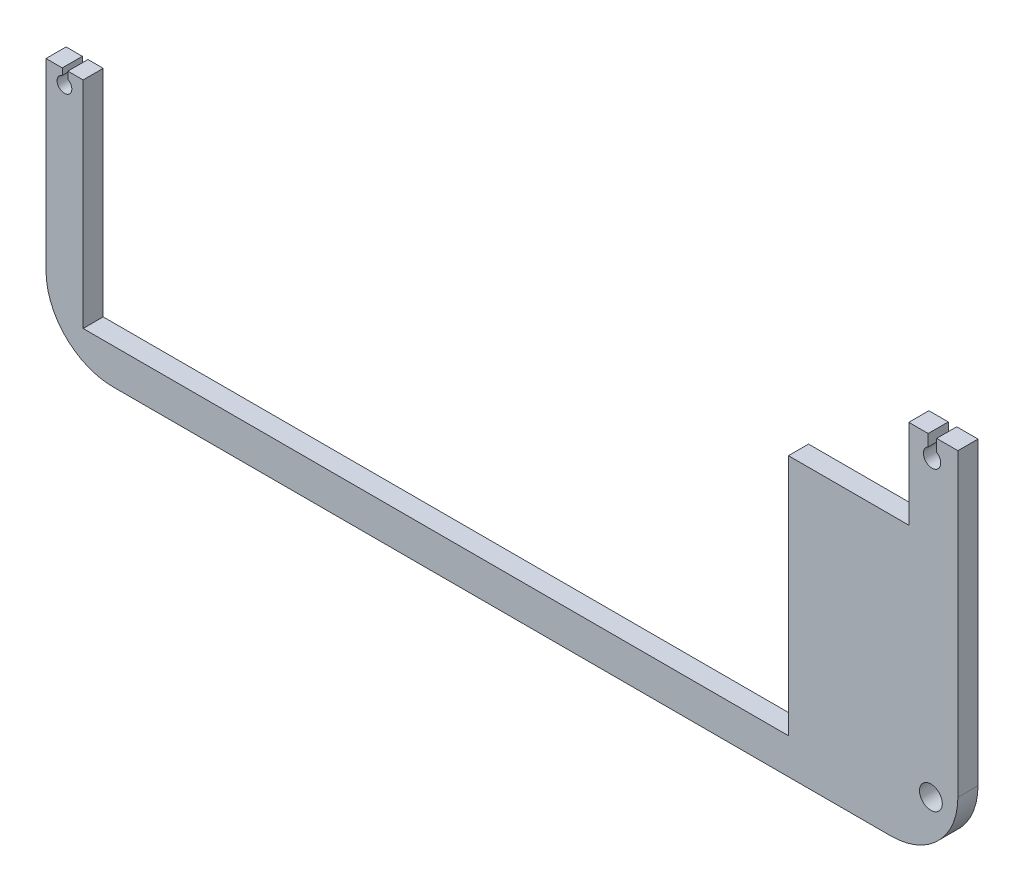
from build123d import *

# Parameters (mm, degrees)
BOSS_EXTRUDE1_DEPTH  = 3
M3_CLEARANCE_HOLE1_D = 3.4
CUT_EXTRUDE1_DEPTH   = 10


with BuildPart() as part:
    # Sketch1 → Boss-Extrude1 (new body)
    with BuildSketch(Plane.XY):
        with BuildLine():
            Line((-93.536600288, 73.798841742), (22.52665856, 73.798841742))
            ThreePointArc((22.52665856, 73.798841742), (29.597726372, 76.72777393), (32.52665856, 83.798841742))
            Line((32.52665856, 83.798841742), (32.52665856, 133.798841742))
            ThreePointArc((32.52665856, 133.798841742), (29.597726372, 140.869909554), (22.52665856, 143.798841742))
            Line((22.52665856, 143.798841742), (-93.536600288, 143.798841742))
            ThreePointArc((-93.536600288, 143.798841742), (-100.6076681, 140.869909554), (-103.536600288, 133.798841742))
            Line((-103.536600288, 133.798841742), (-103.536600288, 83.798841742))
            ThreePointArc((-103.536600288, 83.798841742), (-100.6076681, 76.72777393), (-93.536600288, 73.798841742))
        make_face()
        Polygon((7.241251279, 79.113754803), (7.241251279, 115.298841742), (25.200464445, 115.298841742), (25.200464445, 141.298841742), (-63.686125174, 141.298841742), (-63.686125174, 139.298841742), (-98, 139.298841742), (-98, 79.113754803), align=None, mode=Mode.SUBTRACT)
    extrude(amount=BOSS_EXTRUDE1_DEPTH)

    # M3 Clearance Hole1 (through all)
    with Locations(Plane(origin=(0, 0, 0), x_dir=(-1, 0, 0), z_dir=(0, 0, -1))):
        with Locations((-28.497536526, 136.798841742), (-28.497536526, 81.798841742)):
            Hole(M3_CLEARANCE_HOLE1_D / 2)

    # Sketch2 → Cut-Extrude1 (cut)
    with BuildSketch(Plane.XY.offset(3)):
        with BuildLine():
            Line((-98, 111.232980273), (-100.276015927, 111.232980273))
            Line((-100.276015927, 111.232980273), (-100.276015927, 110.181279495))
            ThreePointArc((-100.276015927, 110.181279495), (-100.885260547, 108.11074669), (-101.110575194, 110.257259772))
            Line((-101.110575194, 110.257259772), (-101.110575194, 111.232980273))
            Line((-101.110575194, 111.232980273), (-103.536600288, 111.232980273))
            Line((-103.536600288, 111.232980273), (-103.536600288, 155.169137996))
            Line((-103.536600288, 155.169137996), (37.520914888, 146.495442913))
            Line((37.520914888, 146.495442913), (36.419995989, 128.591552724))
            Line((36.419995989, 128.591552724), (32.52665856, 128.591552724))
            Line((32.52665856, 128.591552724), (29.357018022, 128.591552724))
            Line((29.357018022, 128.591552724), (29.357018022, 126.79555932))
            ThreePointArc((29.357018022, 126.79555932), (28.609769319, 124.402587901), (28.09640217, 126.856390462))
            Line((28.09640217, 126.856390462), (28.09640217, 128.591552724))
            Line((28.09640217, 128.591552724), (25.200464445, 128.591552724))
            Line((25.200464445, 128.591552724), (-98, 111.232980273))
        make_face()
    extrude(amount=-CUT_EXTRUDE1_DEPTH, mode=Mode.SUBTRACT)


solid = part.part
